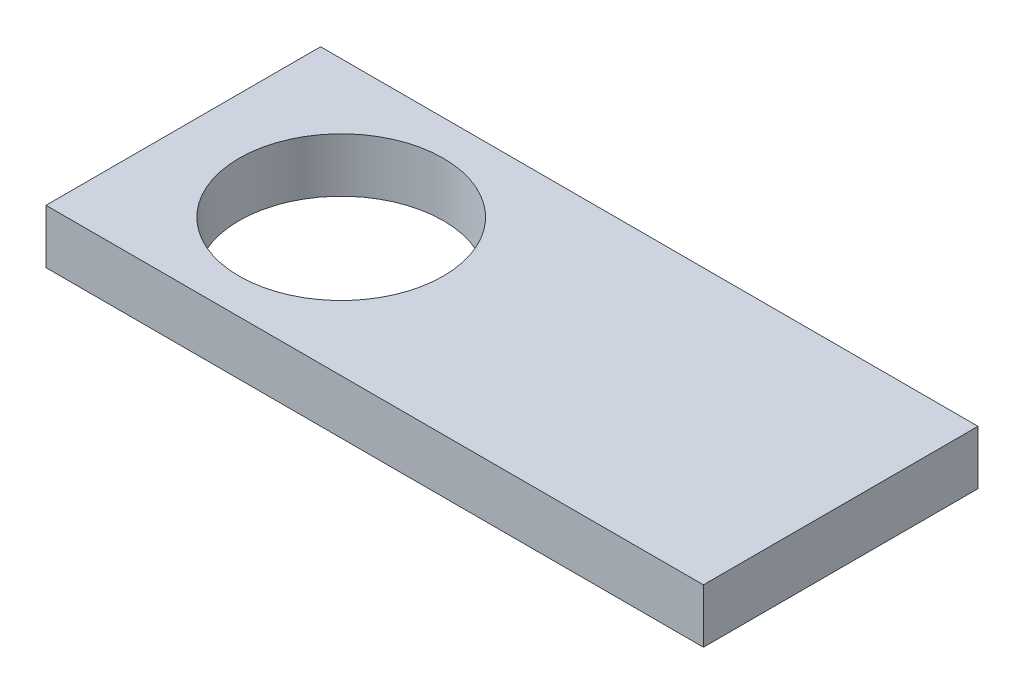
from build123d import *

# Parameters (mm, degrees)
SKETCH1_W           = 76.61
SKETCH1_H           = 32
BOSS_EXTRUDE2_DEPTH = 6.3
SKETCH2_R           = 11.9
CUT_EXTRUDE1_DEPTH  = 6.3


with BuildPart() as part:
    # Sketch1 → Boss-Extrude2 (new body)
    with BuildSketch(Plane(origin=(0, 0, 0), x_dir=(1, 0, 0), z_dir=(0, 1, 0))):
        with Locations((38.305, 16)):
            Rectangle(SKETCH1_W, SKETCH1_H)
    extrude(amount=BOSS_EXTRUDE2_DEPTH)

    # Sketch2 → Cut-Extrude1 (cut)
    with BuildSketch(Plane(origin=(0, 6.3, 0), x_dir=(1, 0, 0), z_dir=(0, 1, 0))):
        with Locations((18.4, 16)):
            Circle(SKETCH2_R)
    extrude(amount=-CUT_EXTRUDE1_DEPTH, mode=Mode.SUBTRACT)


solid = part.part
